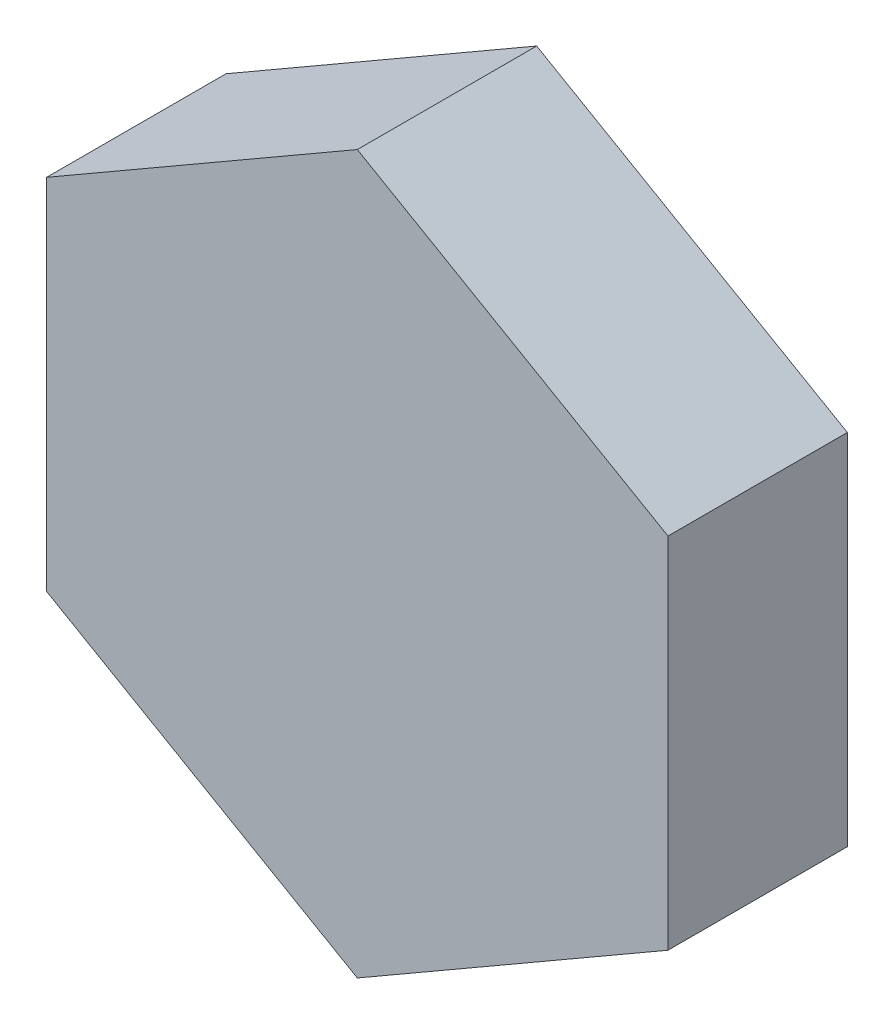
from build123d import *

# Parameters (mm, degrees)
BOSS_EXTRUDE1_DEPTH = 25.4


with BuildPart() as part:
    # Sketch1 → Boss-Extrude1 (new body)
    with BuildSketch(Plane.XY):
        Polygon((43.994090512, -25.4), (43.994090512, 25.4), (0, 50.8), (-43.994090512, 25.4), (-43.994090512, -25.4), (0, -50.8), align=None)
    extrude(amount=BOSS_EXTRUDE1_DEPTH)


solid = part.part
